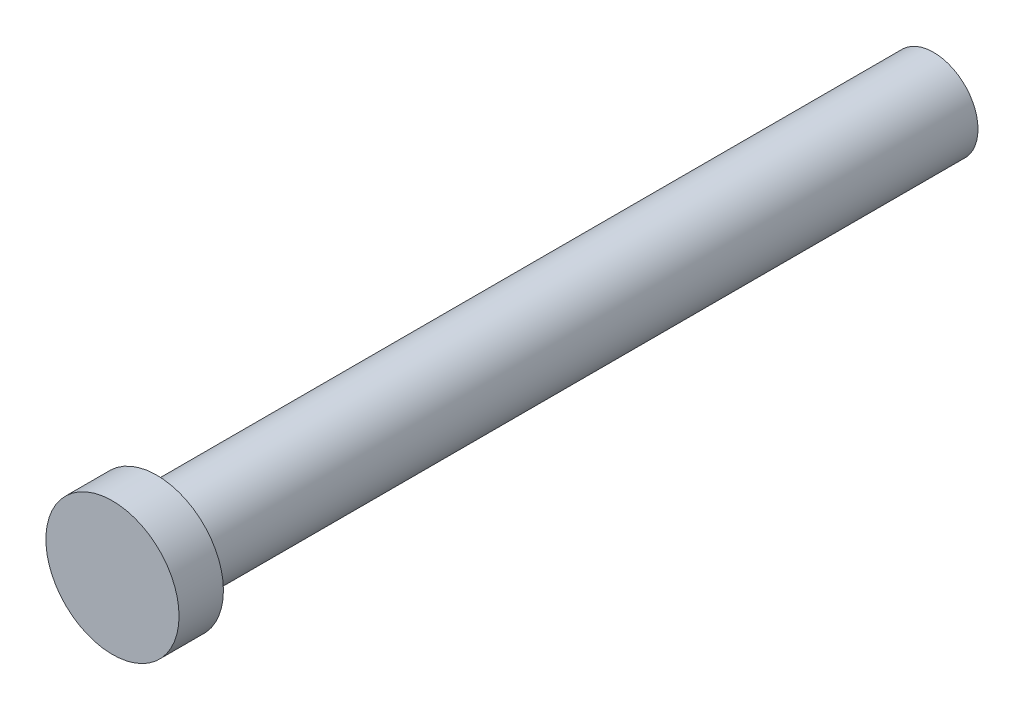
from build123d import *

# Parameters (mm, degrees)
SKETCH1_R           = 2
BOSS_EXTRUDE2_DEPTH = 35
SKETCH3_R           = 3
BOSS_EXTRUDE3_DEPTH = 2


with BuildPart() as part:
    # Sketch1 → Boss-Extrude2 (new body)
    with BuildSketch(Plane.XY):
        Circle(SKETCH1_R)
    extrude(amount=BOSS_EXTRUDE2_DEPTH)

    # Sketch3 → Boss-Extrude3 (add)
    with BuildSketch(Plane.XY.offset(35)):
        Circle(SKETCH3_R)
    extrude(amount=BOSS_EXTRUDE3_DEPTH)


solid = part.part
